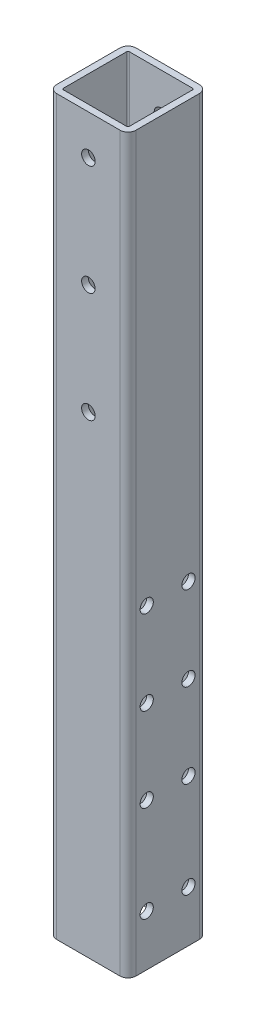
from build123d import *

# Parameters (mm, degrees)
SKETCH1_W               = 38.1
SKETCH1_H               = 38.1
SKETCH1_W_2             = 31.75
SKETCH1_H_2             = 31.75
BOSS_EXTRUDE1_DEPTH     = 176.2125
FILLET1_R               = 3.81
FILLET2_R               = 0.635
SKETCH2_R               = 3.2639
CUT_EXTRUDE1_DEPTH      = 1
CUT_EXTRUDE1_DEPTH_BACK = 39.1
SKETCH5_R               = 3.175
CUT_EXTRUDE3_DEPTH      = 39.1


with BuildPart() as part:
    # Sketch1 → Boss-Extrude1 (new body, symmetric)
    with BuildSketch(Plane(origin=(0, 0, 0), x_dir=(1, 0, 0), z_dir=(0, 1, 0))):
        Rectangle(SKETCH1_W, SKETCH1_H)
        Rectangle(SKETCH1_W_2, SKETCH1_H_2, mode=Mode.SUBTRACT)
    extrude(amount=BOSS_EXTRUDE1_DEPTH, both=True)

    # Fillet1
    fillet1_edges = [part.edges().sort_by_distance(p)[0] for p in [
        (19.05, 0, 19.05),
        (-19.05, 0, 19.05),
        (-19.05, 0, -19.05),
        (19.05, 0, -19.05),
    ]]
    fillet(fillet1_edges, radius=FILLET1_R)

    # Fillet2
    fillet2_edges = [part.edges().sort_by_distance(p)[0] for p in [
        (15.875, 0, -15.875),
        (-15.875, 0, -15.875),
        (-15.875, 0, 15.875),
        (15.875, 0, 15.875),
    ]]
    fillet(fillet2_edges, radius=FILLET2_R)

    # Sketch2 → Cut-Extrude1 (cut, two sides)
    with BuildSketch(Plane.XY.offset(19.05)) as cut_extrude1_sk:
        with Locations((0, 157.1625)):
            Circle(SKETCH2_R)
        with Locations((0, 104.1625)):
            Circle(SKETCH2_R)
        with Locations((0, 51.1625)):
            Circle(SKETCH2_R)
    extrude(amount=CUT_EXTRUDE1_DEPTH, mode=Mode.SUBTRACT)
    extrude(cut_extrude1_sk.sketch, amount=-CUT_EXTRUDE1_DEPTH_BACK, mode=Mode.SUBTRACT)

    # Sketch5 → Cut-Extrude3 (cut, through all)
    with BuildSketch(Plane(origin=(19.05, 0, 0), x_dir=(0, 0, -1), z_dir=(1, 0, 0))):
        with Locations((-10.05, -151.6875)):
            Circle(SKETCH5_R)
        with Locations((-10.05, -24.4875)):
            Circle(SKETCH5_R)
        with Locations((-10.05, -105.4875)):
            Circle(SKETCH5_R)
        with Locations((-10.05, -64.9875)):
            Circle(SKETCH5_R)
        with Locations((10.05, -151.6875)):
            Circle(SKETCH5_R)
        with Locations((10.05, -24.4875)):
            Circle(SKETCH5_R)
        with Locations((10.05, -105.4875)):
            Circle(SKETCH5_R)
        with Locations((10.05, -64.9875)):
            Circle(SKETCH5_R)
    extrude(amount=-CUT_EXTRUDE3_DEPTH, mode=Mode.SUBTRACT)


solid = part.part
